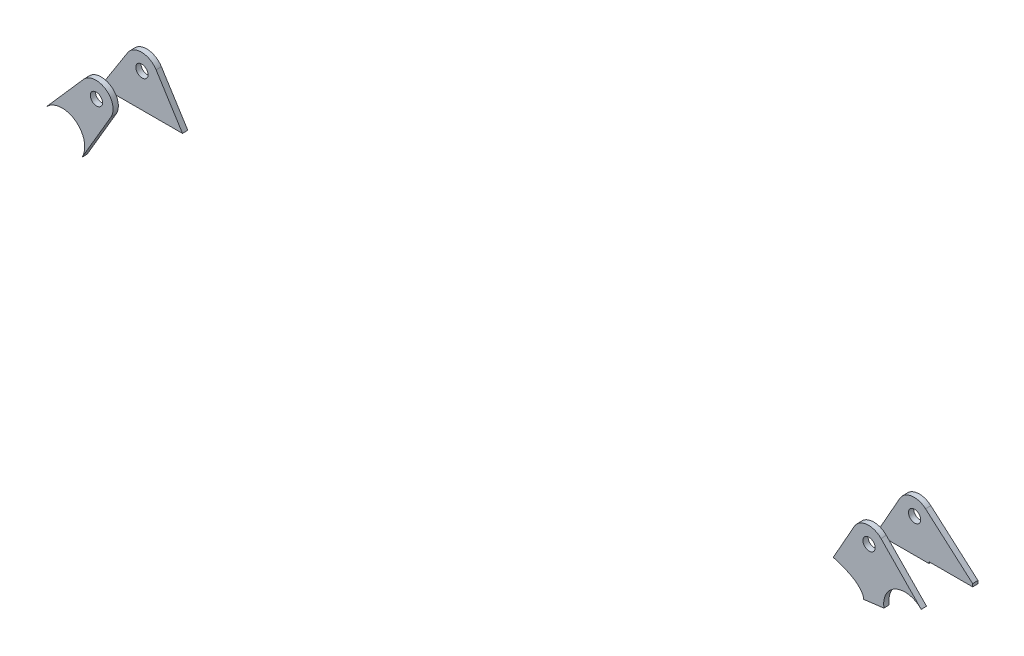
from build123d import *

# Parameters (mm, degrees)
SZKIC1_R                      = 3.5
DODANIE_WYCI_GNI_CIE1_DEPTH   = 3
DODANIE_WYCI_GNI_CIE1_2_DEPTH = 3
SZKIC2_R                      = 3.5
DODANIE_WYCI_GNI_CIE2_DEPTH   = 3
DODANIE_WYCI_GNI_CIE2_2_DEPTH = 3


with BuildPart() as part:
    # Szkic1 → Dodanie-wyciągnięcie1 (new body)
    with BuildSketch(Plane(origin=(0.125765066, -3.805521466, 118.838710879), x_dir=(0.999999441, 3.3854e-05, -0.001057199), z_dir=(0.001057741, -0.03200615, 0.999487112))):
        with BuildLine():
            ThreePointArc((-251.965816374, 215.617689907), (-254.503699361, 228.172933409), (-267.237793388, 226.788072858))
            Line((-267.237793388, 226.788072858), (-289.422618248, 201.6277301))
            add(Edge.make_bspline(
                [(-289.422618248, 201.6277301), (-286.808552781, 204.592404537), (-283.407283221, 205.833574434), (-280.193766535, 205.850681883), (-270.834495382, 205.900506817), (-262.792202195, 197.572371375), (-269.462240018, 186.454814776)],
                knots=[0.346618378, 0.346618378, 0.346618378, 0.346618378, 0.5, 0.5, 0.5, 0.821122795, 0.821122795, 0.821122795, 0.821122795], degree=3, weights=[0.574680887, 0.653718133, 0.79549117, 1, 0.571836274, 0.418658812, 0.540467615]))
            Line((-269.462240018, 186.454814776), (-251.965816374, 215.617689907))
        make_face()
        with Locations((-260.112159551, 220.505132271)):
            Circle(SZKIC1_R, mode=Mode.SUBTRACT)
    extrude(amount=DODANIE_WYCI_GNI_CIE1_DEPTH)


with BuildPart() as body_2:
    # Szkic1 → Dodanie-wyci_gni_cie1 2 (new body)
    with BuildSketch(Plane(origin=(0.125765066, -3.805521466, 118.838710879), x_dir=(0.999999441, 3.3854e-05, -0.001057199), z_dir=(0.001057741, -0.03200615, 0.999487112))):
        with BuildLine():
            Line((209.050872979, 202.551210442), (186.91733989, 226.896739247))
            ThreePointArc((186.91733989, 226.896739247), (178.872372552, 229.951697855), (171.660845224, 225.256152606))
            Line((171.660845224, 225.256152606), (158.967522927, 203.27067347))
            add(Edge.make_bspline(
                [(158.967522927, 203.27067347), (170.737920376, 199.98415846), (175.843611608, 195.08979588), (175.844941209, 190.752233729)],
                knots=[0.803274238, 0.803274238, 0.803274238, 0.803274238, 0.990815919, 0.990815919, 0.990815919, 0.990815919], degree=3, weights=[0.522705155, 0.575991236, 0.723069003, 0.963938456]))
            Line((175.844941209, 190.752233729), (187.48923709, 192.242392262))
            add(Edge.make_bspline(
                [(187.48923709, 192.242392262), (186.295981012, 201.566653094), (192.964200275, 206.596365575), (199.816335243, 206.63284354)],
                knots=[0.734440243, 0.734440243, 0.734440243, 0.734440243, 1, 1, 1, 1], degree=3, weights=[0.501936848, 0.479899273, 0.645920324, 1]))
            add(Edge.make_bspline(
                [(199.816335243, 206.63284354), (203.012558551, 206.649858927), (206.408564562, 205.457587631), (209.050872979, 202.551210442)],
                knots=[0, 0, 0, 0, 0.152724288, 0.152724288, 0.152724288, 0.152724288], degree=3, weights=[1, 0.796367616, 0.654934453, 0.575700513]))
        make_face()
        with Locations((179.88808656, 220.506152606)):
            Circle(SZKIC1_R, mode=Mode.SUBTRACT)
    extrude(amount=DODANIE_WYCI_GNI_CIE1_2_DEPTH)


with BuildPart() as body_3:
    # Szkic2 → Dodanie-wyciągnięcie2 (new body)
    with BuildSketch(Plane(origin=(0.098263803, -2.973361554, 92.852045961), x_dir=(0.999999441, 3.3854e-05, -0.001057199), z_dir=(0.001057741, -0.03200615, 0.999487112))):
        with BuildLine():
            Line((186.372717659, 227.448742865), (212.411687249, 203.127400877))
            add(Edge.make_bspline(
                [(212.411687249, 203.127400877), (212.411680046, 202.573087425), (212.411635073, 202.018774306), (212.411552328, 201.46446403)],
                knots=[0, 0, 0, 0, 0.728559565, 0.728559565, 0.728559565, 0.728559565], degree=3, weights=[1, 0.999997926, 0.999997363, 0.999998311]))
            Line((212.411552328, 201.46446403), (187.401609388, 201.46446403))
            Line((187.401609388, 201.46446403), (187.401609388, 200.538693566))
            Line((187.401609388, 200.538693566), (157.390213594, 200.538693566))
            Line((157.390213594, 200.538693566), (171.660845224, 225.256152606))
            ThreePointArc((171.660845224, 225.256152606), (178.487716745, 229.902373356), (186.372717659, 227.448742865))
        make_face()
        with Locations((179.88808656, 220.506152606)):
            Circle(SZKIC2_R, mode=Mode.SUBTRACT)
    extrude(amount=DODANIE_WYCI_GNI_CIE2_DEPTH)


with BuildPart() as body_4:
    # Szkic2 → Dodanie-wyci_gni_cie2 2 (new body)
    with BuildSketch(Plane(origin=(0.098263803, -2.973361554, 92.852045961), x_dir=(0.999999441, 3.3854e-05, -0.001057199), z_dir=(0.001057741, -0.03200615, 0.999487112))):
        with BuildLine():
            Line((-268.078773116, 225.680368333), (-284.385378892, 200.578435743))
            Line((-284.385378892, 200.578435743), (-237.635870616, 200.57505787))
            Line((-237.635870616, 200.57505787), (-251.884918215, 225.255132271))
            ThreePointArc((-251.884918215, 225.255132271), (-259.862784059, 230.001858647), (-268.078773116, 225.680368333))
        make_face()
        with Locations((-260.112159551, 220.505132271)):
            Circle(SZKIC2_R, mode=Mode.SUBTRACT)
    extrude(amount=DODANIE_WYCI_GNI_CIE2_2_DEPTH)


solid = Compound([part.part, body_2.part, body_3.part, body_4.part])
